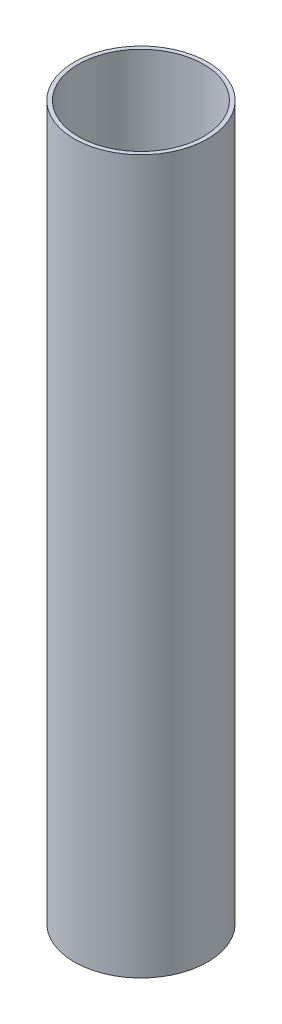
from build123d import *

# Parameters (mm, degrees)
SKETCH1_R           = 50
SKETCH1_R_2         = 47
BOSS_EXTRUDE1_DEPTH = 535


with BuildPart() as part:
    # Sketch1 → Boss-Extrude1 (new body)
    with BuildSketch(Plane(origin=(0, 0, 0), x_dir=(1, 0, 0), z_dir=(0, 1, 0))):
        Circle(SKETCH1_R)
        Circle(SKETCH1_R_2, mode=Mode.SUBTRACT)
    extrude(amount=BOSS_EXTRUDE1_DEPTH)


solid = part.part
